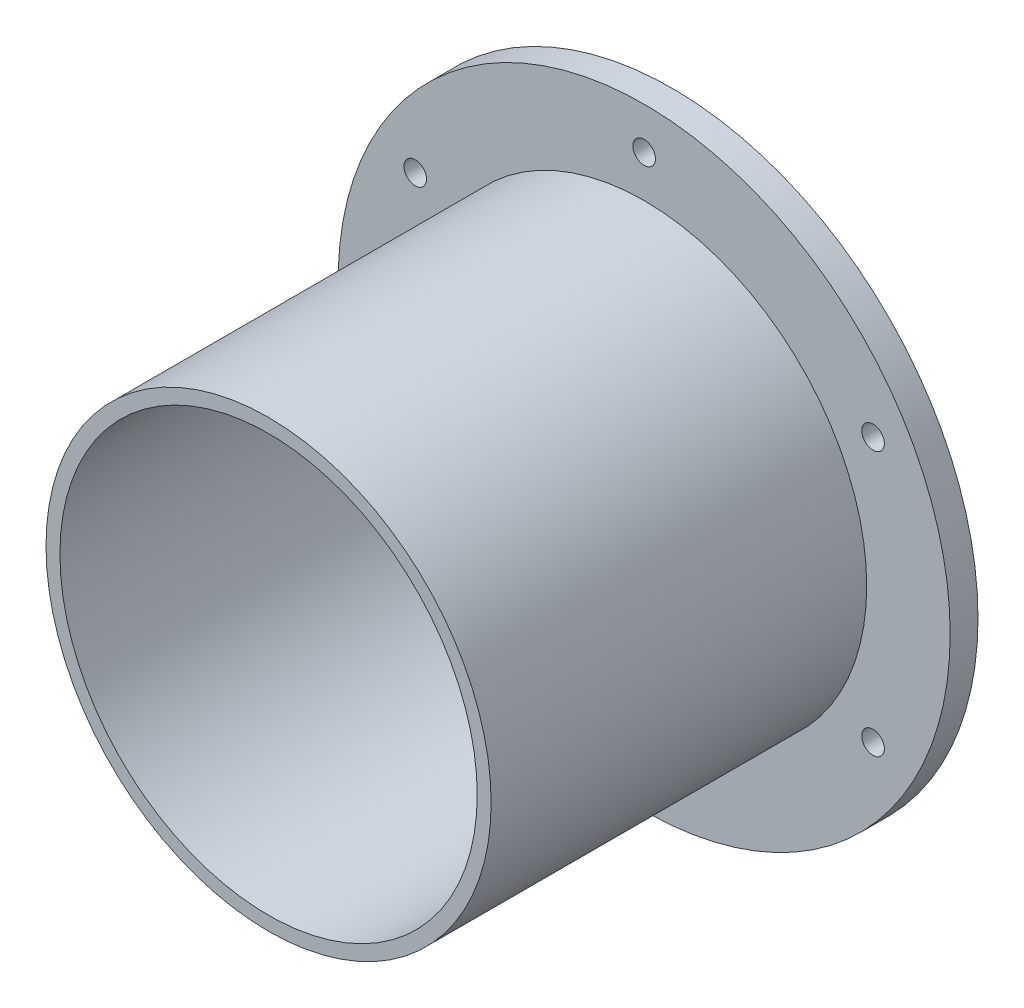
from build123d import *

# Parameters (mm, degrees)
SKETCH1_R      = 69.85
SKETCH1_R_2    = 50.8
SKETCH1_R_3    = 2.57937
EXTRUDE1_DEPTH = 6.35
SKETCH2_R      = 50.8
SKETCH2_R_2    = 47.625
EXTRUDE2_DEPTH = 92.075


with BuildPart() as part:
    # Sketch1 → Extrude1 (new body)
    with BuildSketch(Plane.XY):
        Circle(SKETCH1_R)
        Circle(SKETCH1_R_2, mode=Mode.SUBTRACT)
        with Locations((0, 60.325)):
            Circle(SKETCH1_R_3, mode=Mode.SUBTRACT)
        with Locations((-52.242982483, 30.1625)):
            Circle(SKETCH1_R_3, mode=Mode.SUBTRACT)
        with Locations((-52.242982483, -30.1625)):
            Circle(SKETCH1_R_3, mode=Mode.SUBTRACT)
        with Locations((0, -60.325)):
            Circle(SKETCH1_R_3, mode=Mode.SUBTRACT)
        with Locations((52.242982483, -30.1625)):
            Circle(SKETCH1_R_3, mode=Mode.SUBTRACT)
        with Locations((52.242982483, 30.1625)):
            Circle(SKETCH1_R_3, mode=Mode.SUBTRACT)
    extrude(amount=EXTRUDE1_DEPTH)

    # Sketch2 → Extrude2 (add)
    with BuildSketch(Plane.XY):
        Circle(SKETCH2_R)
        Circle(SKETCH2_R_2, mode=Mode.SUBTRACT)
    extrude(amount=EXTRUDE2_DEPTH)


solid = part.part
